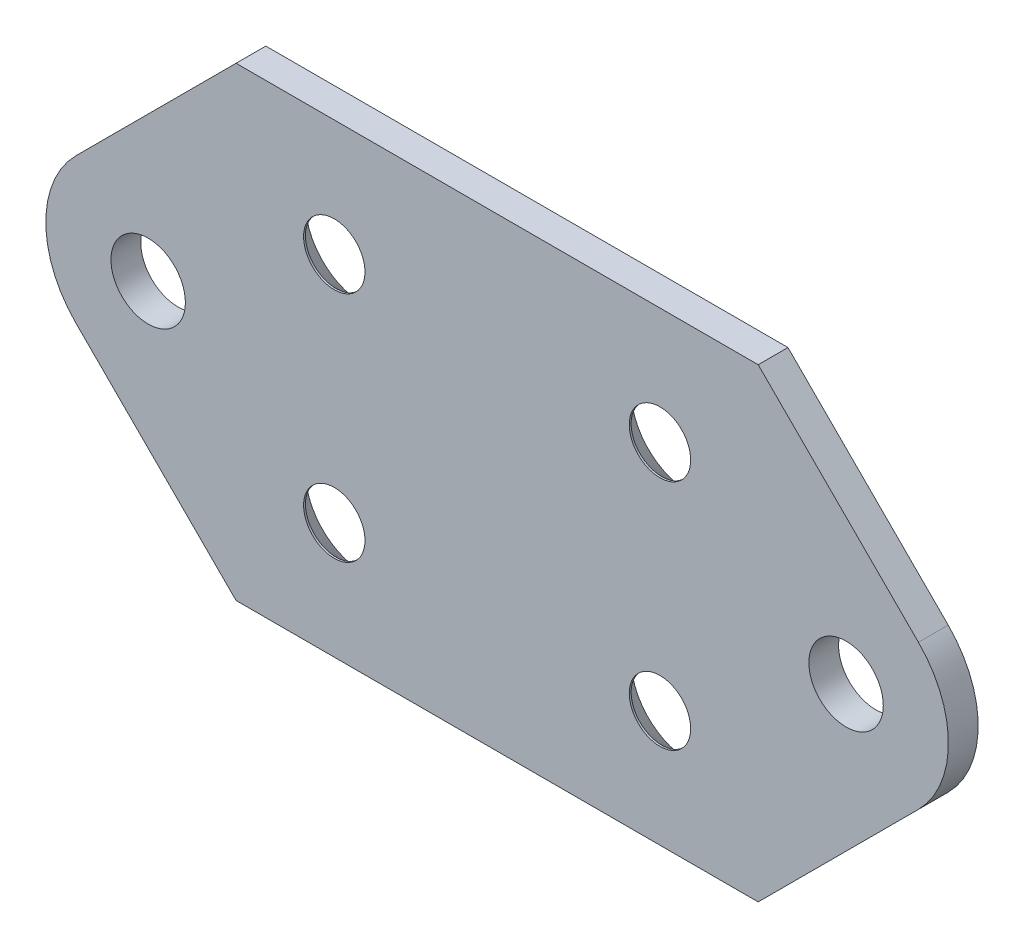
from build123d import *

# Parameters (mm, degrees)
SKETCH1_R                                      = 4
BOSS_EXTRUDE1_DEPTH                            = 3.2
CSK_FOR_M6_FLAT_HEAD_MACHINE_SCREW1_AT_2_COUNT = 2
CSK_FOR_M6_FLAT_HEAD_MACHINE_SCREW1_AT_2_PITCH = 25
CSK_FOR_M6_FLAT_HEAD_MACHINE_SCREW1_AT_3_COUNT = 2
CSK_FOR_M6_FLAT_HEAD_MACHINE_SCREW1_AT_3_PITCH = 43.011626335
CSK_FOR_M6_FLAT_HEAD_MACHINE_SCREW1_AT_4_COUNT = 2
CSK_FOR_M6_FLAT_HEAD_MACHINE_SCREW1_AT_4_PITCH = 35


with BuildPart() as part:
    # Sketch1 → Boss-Extrude1 (new body)
    with BuildSketch(Plane.XY):
        with BuildLine():
            Line((9.443650814, 25), (65.556349186, 25))
            Line((65.556349186, 25), (82.778174593, 7.778174593))
            ThreePointArc((82.778174593, 7.778174593), (86, 0), (82.778174593, -7.778174593))
            Line((82.778174593, -7.778174593), (65.556349186, -25))
            Line((65.556349186, -25), (9.443650814, -25))
            Line((9.443650814, -25), (-7.778174593, -7.778174593))
            ThreePointArc((-7.778174593, -7.778174593), (-11, 0), (-7.778174593, 7.778174593))
            Line((-7.778174593, 7.778174593), (9.443650814, 25))
        make_face()
        Circle(SKETCH1_R, mode=Mode.SUBTRACT)
        with Locations((75, 0)):
            Circle(SKETCH1_R, mode=Mode.SUBTRACT)
    extrude(amount=BOSS_EXTRUDE1_DEPTH)

    # Sketch13 → CSK for M6 Flat Head Machine Screw1 (revolve, cut)
    with BuildSketch(Plane(origin=(20, -12.5, 0), x_dir=(0, 1, 0), z_dir=(1, 0, 0))):
        Polygon((0, 0), (0, 3.2), (3.3, 3.2), (3.3, 3), (6.3, 0), align=None)
    csk_for_m6_flat_head_machine_screw1 = revolve(axis=Axis((20, -12.5, -6.35), (0, 0, 1)), mode=Mode.SUBTRACT)

    # CSK for M6 Flat Head Machine Screw1 at 2: CSK for M6 Flat Head Machine Screw1 ×2
    with Locations(*[(0, i * CSK_FOR_M6_FLAT_HEAD_MACHINE_SCREW1_AT_2_PITCH, 0) for i in range(1, CSK_FOR_M6_FLAT_HEAD_MACHINE_SCREW1_AT_2_COUNT)]):
        add(csk_for_m6_flat_head_machine_screw1, mode=Mode.SUBTRACT)

    # CSK for M6 Flat Head Machine Screw1 at 3: CSK for M6 Flat Head Machine Screw1 ×2
    with Locations(*[Vector(0.813733471, 0.581238194, 0) * (i * CSK_FOR_M6_FLAT_HEAD_MACHINE_SCREW1_AT_3_PITCH) for i in range(1, CSK_FOR_M6_FLAT_HEAD_MACHINE_SCREW1_AT_3_COUNT)]):
        add(csk_for_m6_flat_head_machine_screw1, mode=Mode.SUBTRACT)

    # CSK for M6 Flat Head Machine Screw1 at 4: CSK for M6 Flat Head Machine Screw1 ×2
    with Locations(*[(i * CSK_FOR_M6_FLAT_HEAD_MACHINE_SCREW1_AT_4_PITCH, 0, 0) for i in range(1, CSK_FOR_M6_FLAT_HEAD_MACHINE_SCREW1_AT_4_COUNT)]):
        add(csk_for_m6_flat_head_machine_screw1, mode=Mode.SUBTRACT)


solid = part.part
